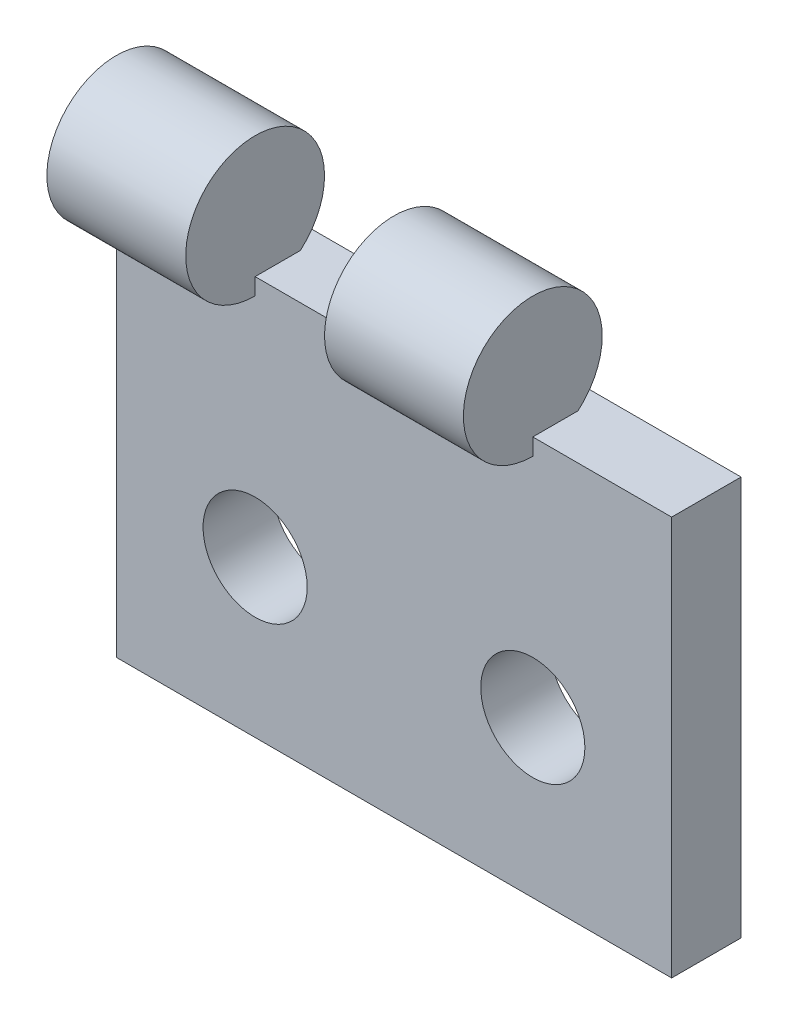
from build123d import *

# Parameters (mm, degrees)
SKETCH1_W             = 16
SKETCH1_H             = 11.5
BOSS_EXTRUDE1_DEPTH   = 2
SKETCH2_R             = 2
BOSS_EXTRUDE2_DEPTH   = 4
LPATTERN1_COUNT       = 2
LPATTERN1_PITCH       = 8
F_3_0MM_DOWEL_HOLE1_D = 3


with BuildPart() as part:
    # Sketch1 → Boss-Extrude1 (new body)
    with BuildSketch(Plane.XY):
        with Locations((8, 5.75)):
            Rectangle(SKETCH1_W, SKETCH1_H)
    extrude(amount=BOSS_EXTRUDE1_DEPTH)

    # Sketch2 → Boss-Extrude2 (add)
    with BuildSketch(Plane(origin=(0, 0, 0), x_dir=(0, 0, -1), z_dir=(1, 0, 0))):
        with Locations((-2, 13.01793751)):
            Circle(SKETCH2_R)
    boss_extrude2 = extrude(amount=BOSS_EXTRUDE2_DEPTH)

    # LPattern1: Boss-Extrude2 ×2
    with Locations(*[(i * LPATTERN1_PITCH, 0, 0) for i in range(1, LPATTERN1_COUNT)]):
        add(boss_extrude2)

    # Ø3.0mm Dowel Hole1 (through all)
    with Locations(Plane.XY.offset(2)):
        with Locations((4, 4.5), (12, 4.5)):
            Hole(F_3_0MM_DOWEL_HOLE1_D / 2)


solid = part.part
